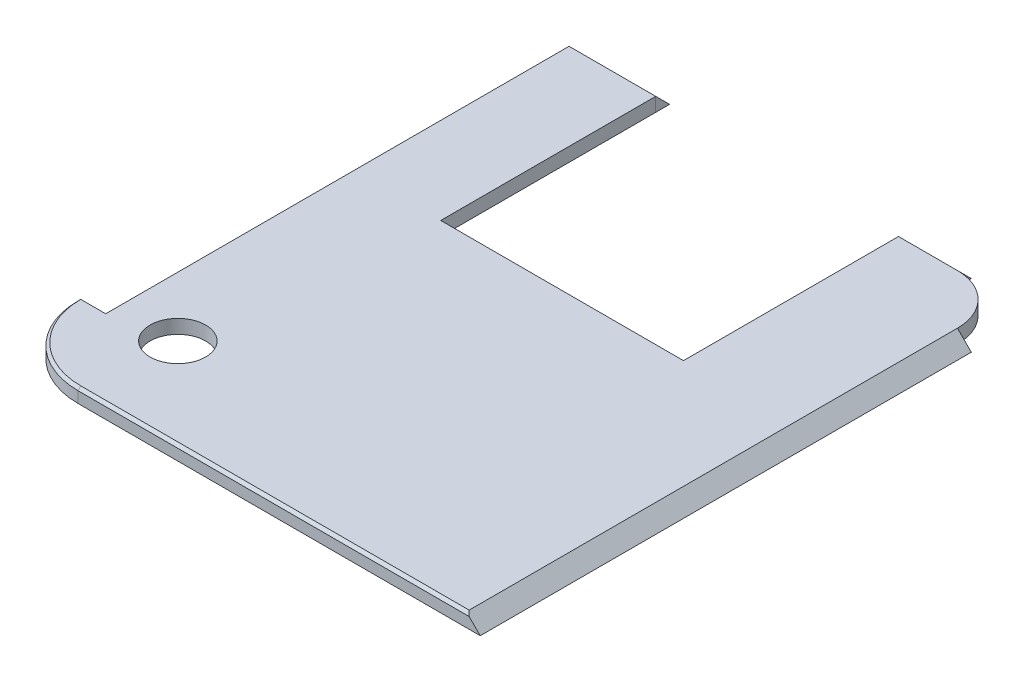
from build123d import *

# Parameters (mm, degrees)
EXTRUDE_1_DEPTH     = 1
EXTRUDE_2_DEPTH     = 33.4
EXTRUDE_3_DEPTH     = 6.25
EXTRUDE_4_DEPTH     = 4.25
EXTRUDE_5_DEPTH     = 35.4
SKETCH_6_W          = 17.5
SKETCH_6_H          = 15.5
CUT_EXTRUDE_1_DEPTH = 2
SKETCH_7_W          = 5.6
SKETCH_7_H          = 5.6
EXTRUDE_6_DEPTH     = 5
CHAMFER_2_SIZE      = 1
CHAMFER_3_SIZE      = 0.2
SKETCH_9_R          = 2
CUT_EXTRUDE_3_DEPTH = 1


with BuildPart() as part:
    # 草图1 → 凸台-拉伸1 (new body)
    with BuildSketch(Plane(origin=(0, 0, 0), x_dir=(1, 0, 0), z_dir=(0, 1, 0))):
        with BuildLine():
            Line((-14.17993762, 18.688260597), (13.82006238, 18.688260597))
            ThreePointArc((13.82006238, 18.688260597), (16.365646792, 17.63384501), (17.42006238, 15.088260597))
            Line((17.42006238, 15.088260597), (17.42006238, -20.311739403))
            Line((17.42006238, -20.311739403), (-10.57993762, -20.311739403))
            ThreePointArc((-10.57993762, -20.311739403), (-14.539735595, -18.671537377), (-16.17993762, -14.711739403))
            Line((-16.17993762, -14.711739403), (-14.17993762, -14.711739403))
            Line((-14.17993762, -14.711739403), (-14.17993762, 18.688260597))
        make_face()
    extrude(amount=EXTRUDE_1_DEPTH)

    # 草图5 → 凸台-拉伸5 (add)
    with BuildSketch(Plane.XY.offset(20.311739403)):
        Polygon((17.42006238, 1), (17.42006238, 0), (18.42006238, 0), align=None)
    extrude(amount=-EXTRUDE_5_DEPTH)

    # 草图6 → 切除-拉伸1 (cut, through all)
    with BuildSketch(Plane(origin=(0, 1, 0), x_dir=(1, 0, 0), z_dir=(0, 1, 0))):
        with Locations((0.82006238, 10.938260597)):
            Rectangle(SKETCH_6_W, SKETCH_6_H)
    extrude(amount=-CUT_EXTRUDE_1_DEPTH, mode=Mode.SUBTRACT)

    # 草图7 → 凸台-拉伸6 (add)
    with BuildSketch(Plane.XZ):
        with Locations((1.62006238, 7.511739403)):
            Rectangle(SKETCH_7_W, SKETCH_7_H)
    extrude(amount=EXTRUDE_6_DEPTH)

    # 倒角2
    chamfer_2_edges = [part.edges().sort_by_distance(p)[0] for p in [
        (4.42006238, -5, 7.511739403),
        (1.62006238, -5, 10.311739403),
        (-1.17993762, -5, 7.511739403),
        (1.62006238, -5, 4.711739403),
    ]]
    chamfer(chamfer_2_edges, length=CHAMFER_2_SIZE)

    # 倒角3
    chamfer_3_edges = [part.edges().sort_by_distance(p)[0] for p in [
        (-14.539735595, 1, 18.671537377),
        (3.42006238, 1, 20.311739403),
    ]]
    chamfer(chamfer_3_edges, length=CHAMFER_3_SIZE)

    # 草图9 → 切除-拉伸3 (cut)
    with BuildSketch(Plane(origin=(0, 1, 0), x_dir=(1, 0, 0), z_dir=(0, 1, 0))):
        with Locations((-9.87993762, -13.811739403)):
            Circle(SKETCH_9_R)
    extrude(amount=-CUT_EXTRUDE_3_DEPTH, mode=Mode.SUBTRACT)


with BuildPart() as body_2:
    # 草图2 → 凸台-拉伸2 (new body)
    with BuildSketch(Plane(origin=(0, 0, 14.711739403), x_dir=(-1, 0, 0), z_dir=(0, 0, -1))):
        Polygon((14.17993762, 1), (14.17993762, 0), (15.17993762, 0), align=None)
    extrude(amount=EXTRUDE_2_DEPTH)


with BuildPart() as body_3:
    # 草图3 → 凸台-拉伸3 (new body)
    with BuildSketch(Plane.ZY.offset(14.17993762)):
        Polygon((-18.688260597, 1), (-18.688260597, 0), (-19.688260597, 0), align=None)
    extrude(amount=-EXTRUDE_3_DEPTH)


with BuildPart() as body_4:
    # 草图4 → 凸台-拉伸4 (new body)
    with BuildSketch(Plane.ZY.offset(-13.82006238)):
        Polygon((-18.688260597, 1), (-18.688260597, 0), (-19.688260597, 0), align=None)
    extrude(amount=EXTRUDE_4_DEPTH)


solid = Compound([part.part, body_2.part, body_3.part, body_4.part])
